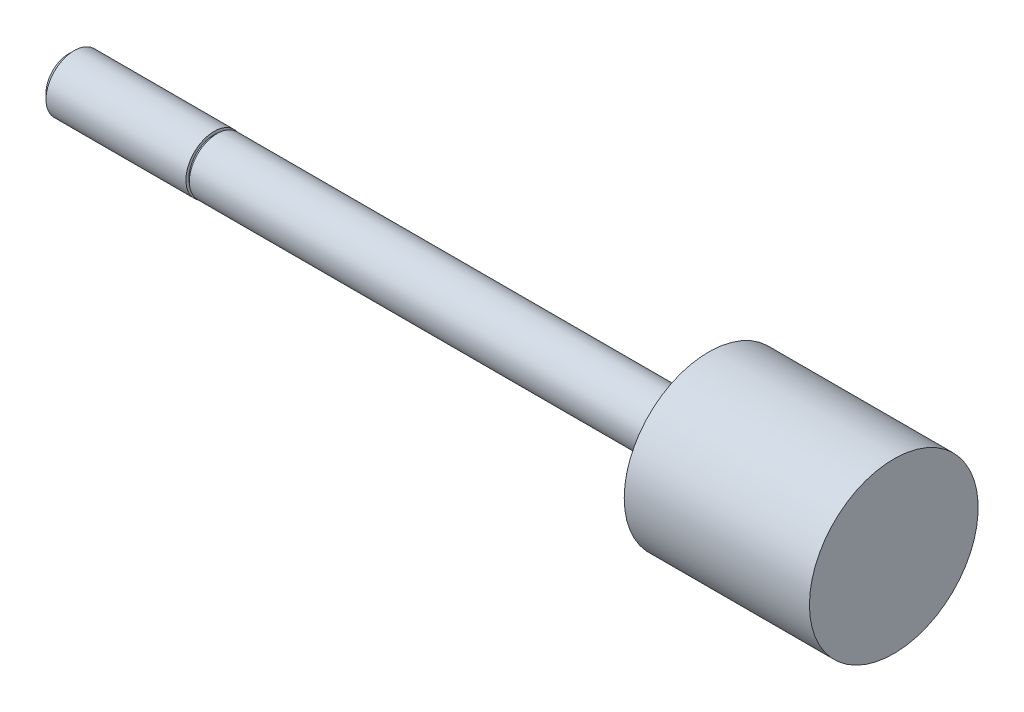
from build123d import *

# Parameters (mm, degrees)
SKETCH3_W = 0.254
SKETCH3_H = 0.508


with BuildPart() as part:
    # Sketch1 → Revolve1 (revolve)
    with BuildSketch(Plane.XY):
        Polygon((0, 0), (0, 2.3749), (42.0624, 2.3749), (42.0624, 7.21995), (57.912, 7.21995), (57.912, 0), align=None)
    revolve(axis=Axis((57.912, 0, 0), (-1, 0, 0)))

    # Sketch2 → Revolve2 (revolve)
    with BuildSketch(Plane.XY):
        Polygon((-12.7, 0), (-12.7, 1.94056), (-12.22756, 2.413), (0, 2.413), (0, 0), align=None)
    revolve(axis=Axis((0, 0, 0), (-1, 0, 0)))

    # Sketch3 → Cut-Revolve1 (revolve, cut)
    with BuildSketch(Plane.XY):
        with Locations((-0.127, 2.413)):
            Rectangle(SKETCH3_W, SKETCH3_H)
    revolve(axis=Axis((0, 0, 0), (-1, 0, 0)), mode=Mode.SUBTRACT)


solid = part.part
